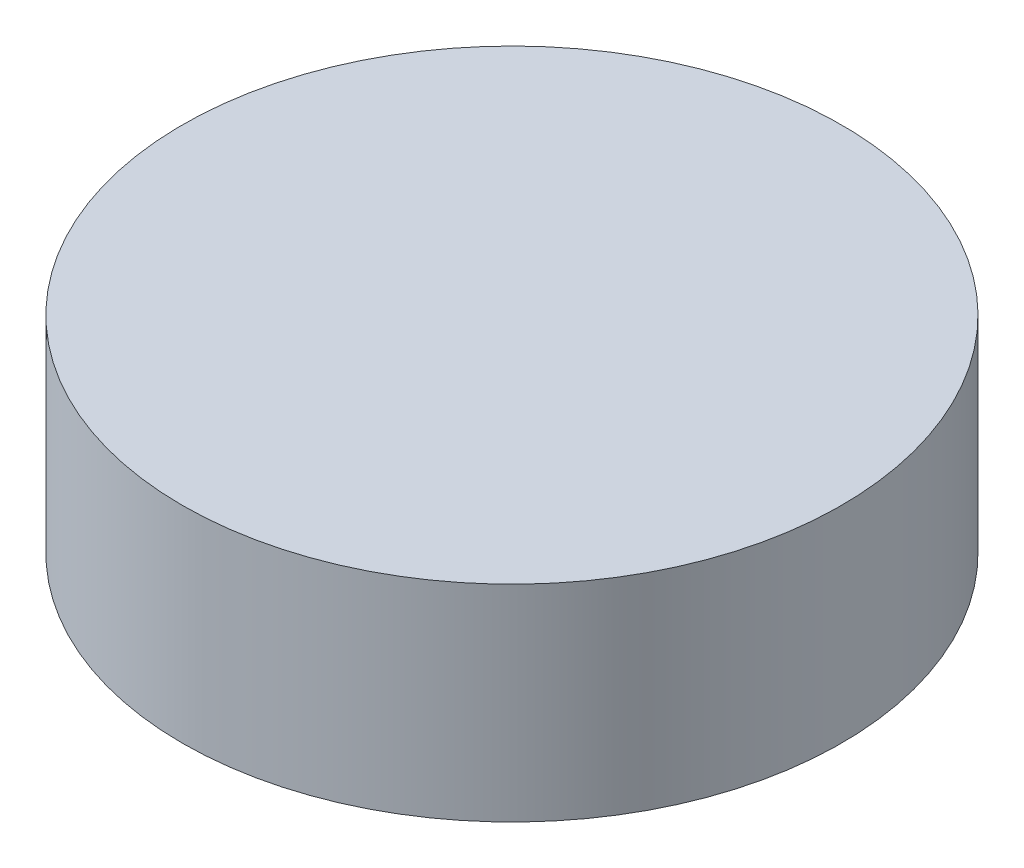
from build123d import *

# Parameters (mm, degrees)
SKETCH1_R           = 0.4
BOSS_EXTRUDE1_DEPTH = 0.25


with BuildPart() as part:
    # Sketch1 → Boss-Extrude1 (new body)
    with BuildSketch(Plane(origin=(0, 0, 0), x_dir=(1, 0, 0), z_dir=(0, 1, 0))):
        Circle(SKETCH1_R)
    extrude(amount=BOSS_EXTRUDE1_DEPTH)


solid = part.part
